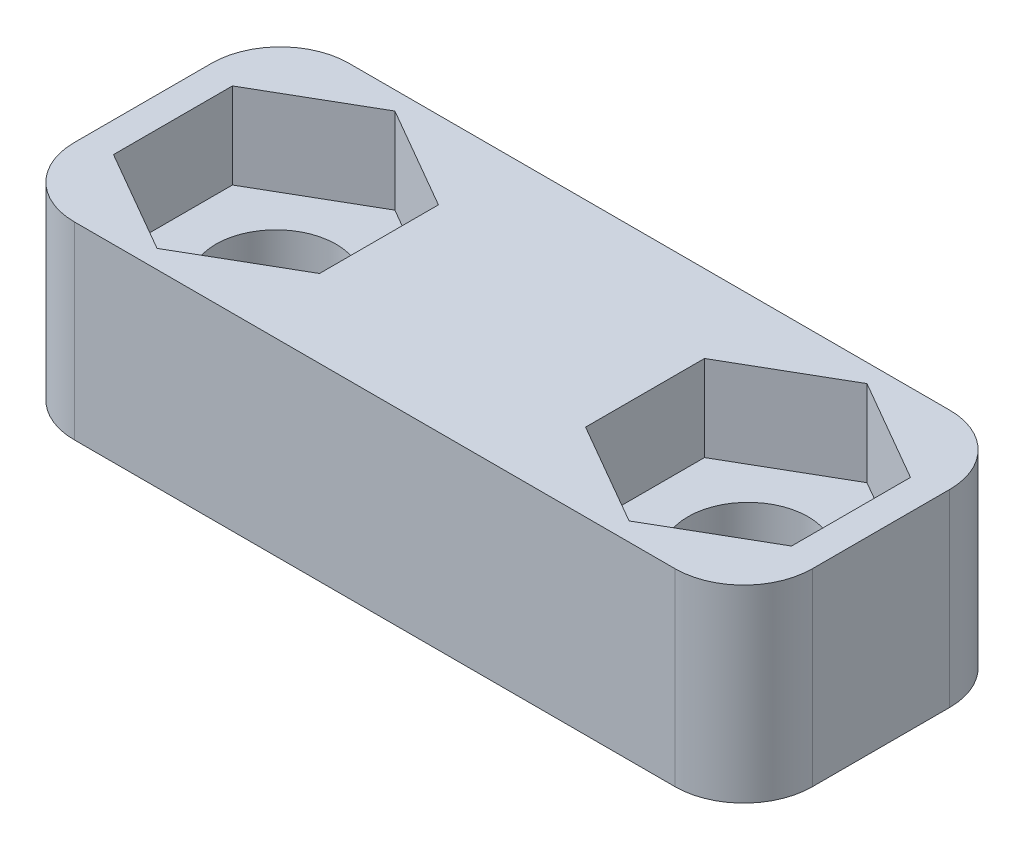
from build123d import *

# Parameters (mm, degrees)
SKETCH1_W           = 21.5
SKETCH1_H           = 5.5
BOSS_EXTRUDE1_DEPTH = 8
SKETCH2_R           = 1.75
CUT_EXTRUDE1_DEPTH  = 6.5
CUT_EXTRUDE2_DEPTH  = 2.5
BOSS_EXTRUDE3_DEPTH = 1
BOSS_EXTRUDE4_DEPTH = 1
FILLET1_R           = 2


with BuildPart() as part:
    # Sketch1 → Boss-Extrude1 (new body)
    with BuildSketch(Plane.XY):
        with Locations((10.75, -2.75)):
            Rectangle(SKETCH1_W, SKETCH1_H)
    extrude(amount=BOSS_EXTRUDE1_DEPTH)

    # Sketch2 → Cut-Extrude1 (cut, through all)
    with BuildSketch(Plane.XZ.offset(5.5)):
        with Locations((3.875, 4)):
            Circle(SKETCH2_R)
        with Locations((17.625, 4)):
            Circle(SKETCH2_R)
    extrude(amount=-CUT_EXTRUDE1_DEPTH, mode=Mode.SUBTRACT)

    # Sketch3 → Cut-Extrude2 (cut)
    with BuildSketch(Plane(origin=(0, 0, 0), x_dir=(1, 0, 0), z_dir=(0, 1, 0))):
        Polygon((6.875, -5.732050808), (6.875, -2.267949192), (3.875, -0.535898385), (0.875, -2.267949192), (0.875, -5.732050808), (3.875, -7.464101615), align=None)
        Polygon((20.625, -2.267949192), (17.625, -0.535898385), (14.625, -2.267949192), (14.625, -5.732050808), (17.625, -7.464101615), (20.625, -5.732050808), align=None)
    extrude(amount=-CUT_EXTRUDE2_DEPTH, mode=Mode.SUBTRACT)

    # Sketch4 → Boss-Extrude3 (add)
    with BuildSketch(Plane.XY.offset(1)):
        Polygon((7.5, -5.5), (14, -5.5), (12.5, -6.5), (9, -6.5), align=None)
    extrude(amount=BOSS_EXTRUDE3_DEPTH)

    # Sketch5 → Boss-Extrude4 (add)
    with BuildSketch(Plane.XY.offset(7)):
        Polygon((7.5, -5.5), (9, -6.5), (12.5, -6.5), (14, -5.5), align=None)
    extrude(amount=-BOSS_EXTRUDE4_DEPTH)

    # Fillet1
    fillet1_edges = [part.edges().sort_by_distance(p)[0] for p in [
        (21.5, -2.75, 8),
        (21.5, -2.75, 0),
        (0, -2.75, 0),
        (0, -2.75, 8),
    ]]
    fillet(fillet1_edges, radius=FILLET1_R)


solid = part.part
